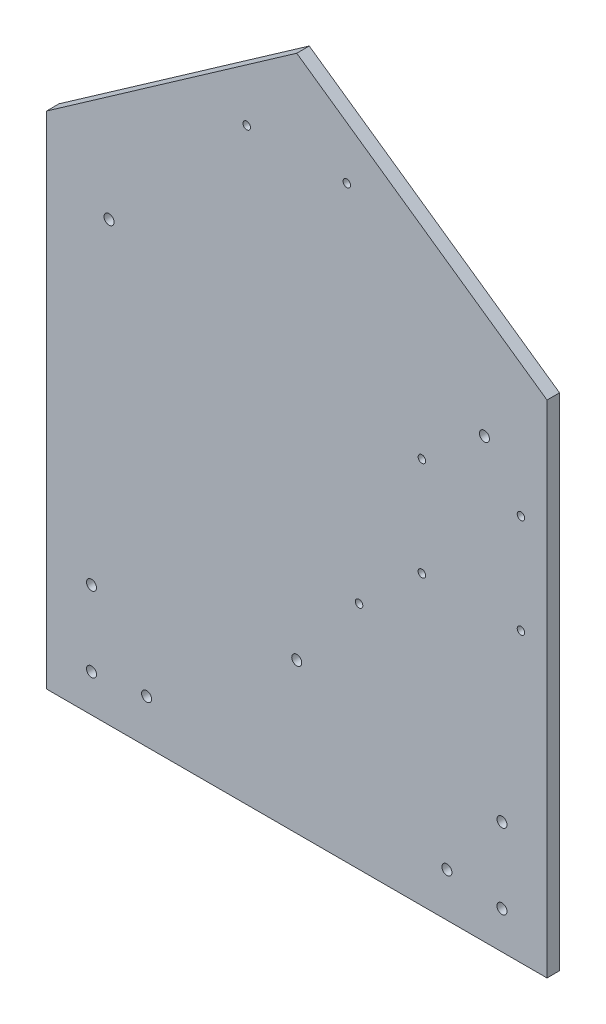
from build123d import *

# Parameters (mm, degrees)
SKETCH1_R           = 2
SKETCH1_R_2         = 1.5
BOSS_EXTRUDE1_DEPTH = 5


with BuildPart() as part:
    # Sketch1 → Boss-Extrude1 (new body)
    with BuildSketch(Plane.XY):
        Polygon((-92.496965253, 104.871794872), (-92.496965253, -95.128205128), (107.503034747, -95.128205128), (107.503034747, 104.871794872), (7.503034747, 174.871794872), align=None)
        with Locations((89.503034747, -80.128205128)):
            Circle(SKETCH1_R, mode=Mode.SUBTRACT)
        with Locations((-74.496965253, -80.128205128)):
            Circle(SKETCH1_R, mode=Mode.SUBTRACT)
        with Locations((27.503034747, 139.871794872)):
            Circle(SKETCH1_R_2, mode=Mode.SUBTRACT)
        with Locations((-12.496965253, 139.871794872)):
            Circle(SKETCH1_R_2, mode=Mode.SUBTRACT)
        with Locations((89.503034747, -50.128205128)):
            Circle(SKETCH1_R, mode=Mode.SUBTRACT)
        with Locations((-74.496965253, -50.128205128)):
            Circle(SKETCH1_R, mode=Mode.SUBTRACT)
        with Locations((7.503034747, -35.128205128)):
            Circle(SKETCH1_R, mode=Mode.SUBTRACT)
        with Locations((32.403034747, -3.128205128)):
            Circle(SKETCH1_R_2, mode=Mode.SUBTRACT)
        with Locations((57.503034747, 19.871794872)):
            Circle(SKETCH1_R_2, mode=Mode.SUBTRACT)
        with Locations((-52.496965253, -77.628205128)):
            Circle(SKETCH1_R, mode=Mode.SUBTRACT)
        with Locations((67.503034747, -77.628205128)):
            Circle(SKETCH1_R, mode=Mode.SUBTRACT)
        with Locations((-67.496965253, 79.871794872)):
            Circle(SKETCH1_R, mode=Mode.SUBTRACT)
        with Locations((82.503034747, 79.871794872)):
            Circle(SKETCH1_R, mode=Mode.SUBTRACT)
        with Locations((57.503034747, 59.471794872)):
            Circle(SKETCH1_R_2, mode=Mode.SUBTRACT)
        with Locations((97.103034747, 19.871794872)):
            Circle(SKETCH1_R_2, mode=Mode.SUBTRACT)
        with Locations((97.103034747, 59.471794872)):
            Circle(SKETCH1_R_2, mode=Mode.SUBTRACT)
    extrude(amount=BOSS_EXTRUDE1_DEPTH)


solid = part.part
